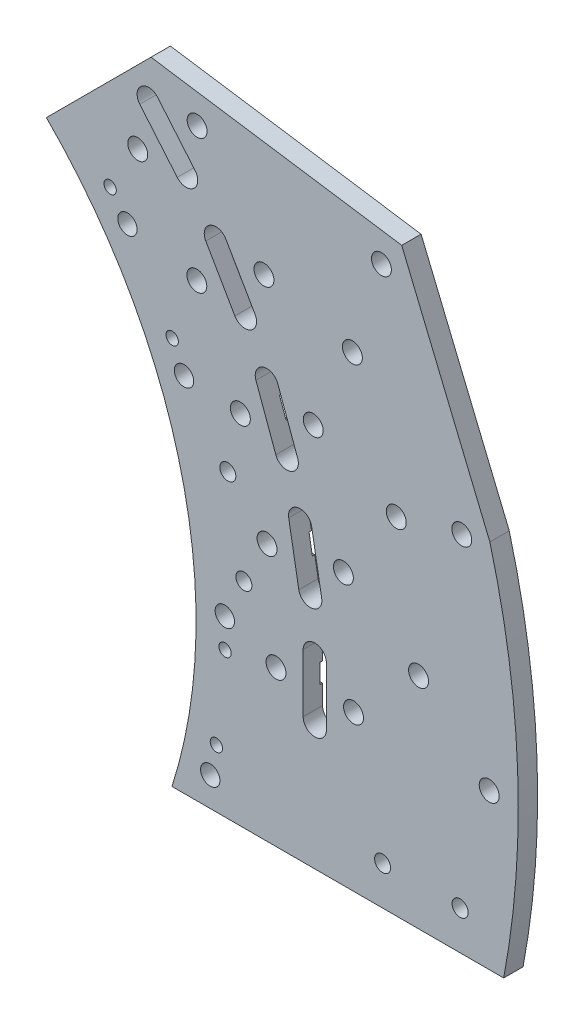
from build123d import *

# Parameters (mm, degrees)
SKETCH1_R           = 3.175
SKETCH1_R_2         = 3.2639
SKETCH1_R_3         = 2.6289
SKETCH1_R_4         = 2.0193
BOSS_EXTRUDE1_DEPTH = 6.35
SKETCH2_R           = 3.175
CUT_EXTRUDE1_DEPTH  = 0.79375


with BuildPart() as part:
    # Sketch1 → Boss-Extrude1 (new body)
    with BuildSketch(Plane.XY):
        with BuildLine():
            Line((159.591131024, -50.8), (268.282803213, -50.8))
            ThreePointArc((268.282803213, -50.8), (272.859757692, 10.190933821), (263.746046868, 70.670540265))
            Line((263.746046868, 70.670540265), (234.864133392, 140.397647486))
            Line((234.864133392, 140.397647486), (234.123018172, 140.508771477))
            Line((234.123018172, 140.508771477), (152.715190262, 152.715190262))
            Line((152.715190262, 152.715190262), (118.427127597, 118.427127597))
            ThreePointArc((118.427127597, 118.427127597), (154.732498954, 64.092299607), (167.48125, 0))
            ThreePointArc((167.48125, 0), (165.496965553, -25.70454229), (159.591131024, -50.8))
        make_face()
        with Locations((176.898422575, 6.177429038)):
            Circle(SKETCH1_R, mode=Mode.SUBTRACT)
        with Locations((144.995031539, 101.526614087)):
            Circle(SKETCH1_R, mode=Mode.SUBTRACT)
        with Locations((163.532451502, 67.7373593)):
            Circle(SKETCH1_R, mode=Mode.SUBTRACT)
        with Locations((172.12665951, -41.275)):
            Circle(SKETCH1_R, mode=Mode.SUBTRACT)
        with Locations((193.675, 0)):
            Circle(SKETCH1_R_2, mode=Mode.SUBTRACT)
        with Locations((219.075, 0)):
            Circle(SKETCH1_R_2, mode=Mode.SUBTRACT)
        with Locations((215.746758491, 38.041974522)):
            Circle(SKETCH1_R_2, mode=Mode.SUBTRACT)
        with Locations((190.732641565, 33.63131081)):
            Circle(SKETCH1_R_2, mode=Mode.SUBTRACT)
        with Locations((205.863160899, 74.928062899)):
            Circle(SKETCH1_R_2, mode=Mode.SUBTRACT)
        with Locations((181.994968331, 66.240751259)):
            Circle(SKETCH1_R_2, mode=Mode.SUBTRACT)
        with Locations((189.724515334, 109.5375)):
            Circle(SKETCH1_R_2, mode=Mode.SUBTRACT)
        with Locations((167.727470078, 96.8375)):
            Circle(SKETCH1_R_2, mode=Mode.SUBTRACT)
        with Locations((167.821186376, 140.818695592)):
            Circle(SKETCH1_R_2, mode=Mode.SUBTRACT)
        with Locations((148.363657521, 124.491890306)):
            Circle(SKETCH1_R_2, mode=Mode.SUBTRACT)
        with Locations((263.525, 0)):
            Circle(SKETCH1_R_2, mode=Mode.SUBTRACT)
        with Locations((254.545603373, 68.205288861)):
            Circle(SKETCH1_R_2, mode=Mode.SUBTRACT)
        with Locations((228.219344532, 131.7625)):
            Circle(SKETCH1_R_2, mode=Mode.SUBTRACT)
        with Locations((177.875240911, 47.661527156)):
            Circle(SKETCH1_R_3, mode=Mode.SUBTRACT)
        with Locations((183.141207032, 19.248916511)):
            Circle(SKETCH1_R_3, mode=Mode.SUBTRACT)
        with Locations((139.323763183, 109.179217581)):
            Circle(SKETCH1_R_4, mode=Mode.SUBTRACT)
        with Locations((159.651941396, 76.436052669)):
            Circle(SKETCH1_R_4, mode=Mode.SUBTRACT)
        with Locations((176.974598028, -3.347266353)):
            Circle(SKETCH1_R_4, mode=Mode.SUBTRACT)
        with Locations((174.135237045, -31.751090662)):
            Circle(SKETCH1_R_4, mode=Mode.SUBTRACT)
        with Locations((240.38178065, 21.030680725)):
            Circle(SKETCH1_R_2, mode=Mode.SUBTRACT)
        with Locations((233.077901884, 62.453035583)):
            Circle(SKETCH1_R_2, mode=Mode.SUBTRACT)
        with Locations((218.692069012, 101.977786558)):
            Circle(SKETCH1_R_2, mode=Mode.SUBTRACT)
        with Locations((228.6, -38.1)):
            Circle(SKETCH1_R_3, mode=Mode.SUBTRACT)
        with Locations((254, -38.1)):
            Circle(SKETCH1_R_3, mode=Mode.SUBTRACT)
        with BuildLine():
            Line((202.565, 0), (202.565, 9.525))
            ThreePointArc((202.565, 9.525), (206.375, 13.335), (210.185, 9.525))
            Line((210.185, 9.525), (210.185, 0))
            Line((210.185, 0), (210.185, -9.525))
            ThreePointArc((210.185, -9.525), (206.375, -13.335), (202.565, -9.525))
            Line((202.565, -9.525), (202.565, 0))
        make_face(mode=Mode.SUBTRACT)
        with BuildLine():
            Line((199.487582489, 35.175043109), (201.141581381, 25.794749262))
            ThreePointArc((201.141581381, 25.794749262), (205.555298477, 22.70423128), (208.645816459, 27.117948375))
            Line((208.645816459, 27.117948375), (206.991817567, 36.498242223))
            Line((206.991817567, 36.498242223), (205.337818675, 45.87853607))
            ThreePointArc((205.337818675, 45.87853607), (200.924101579, 48.969054052), (197.833583597, 44.555336957))
            Line((197.833583597, 44.555336957), (199.487582489, 35.175043109))
        make_face(mode=Mode.SUBTRACT)
        with BuildLine():
            Line((190.348835729, 69.281310333), (193.606577595, 60.33073812))
            ThreePointArc((193.606577595, 60.33073812), (198.489903226, 58.053605981), (200.767035365, 62.936931612))
            Line((200.767035365, 62.936931612), (197.5092935, 71.887503825))
            Line((197.5092935, 71.887503825), (194.251551635, 80.838076038))
            ThreePointArc((194.251551635, 80.838076038), (189.368226003, 83.115208177), (187.091093864, 78.231882546))
            Line((187.091093864, 78.231882546), (190.348835729, 69.281310333))
        make_face(mode=Mode.SUBTRACT)
        with BuildLine():
            Line((175.426435918, 101.2825), (180.188935918, 93.033608029))
            ThreePointArc((180.188935918, 93.033608029), (185.393492706, 91.639051241), (186.788049494, 96.843608029))
            Line((186.788049494, 96.843608029), (182.025549494, 105.0925))
            Line((182.025549494, 105.0925), (177.263049494, 113.341391971))
            ThreePointArc((177.263049494, 113.341391971), (172.058492706, 114.735948759), (170.663935918, 109.531391971))
            Line((170.663935918, 109.531391971), (175.426435918, 101.2825))
        make_face(mode=Mode.SUBTRACT)
        with BuildLine():
            Line((155.17379262, 130.206272156), (161.296344603, 122.909698835))
            ThreePointArc((161.296344603, 122.909698835), (166.663994724, 122.4400903), (167.133603259, 127.807740421))
            Line((167.133603259, 127.807740421), (161.011051277, 135.104313742))
            Line((161.011051277, 135.104313742), (154.888499295, 142.400887063))
            ThreePointArc((154.888499295, 142.400887063), (149.520849174, 142.870495598), (149.051240638, 137.502845477))
            Line((149.051240638, 137.502845477), (155.17379262, 130.206272156))
        make_face(mode=Mode.SUBTRACT)
    extrude(amount=BOSS_EXTRUDE1_DEPTH)

    # Sketch2 → Cut-Extrude1 (cut)
    with BuildSketch(Plane.XY):
        with Locations((202.565, 0)):
            Circle(SKETCH2_R)
        with Locations((210.185, 0)):
            Circle(SKETCH2_R)
        with Locations((199.487582489, 35.175043109)):
            Circle(SKETCH2_R)
        with Locations((206.991817567, 36.498242223)):
            Circle(SKETCH2_R)
        with Locations((190.348835729, 69.281310333)):
            Circle(SKETCH2_R)
        with Locations((197.5092935, 71.887503825)):
            Circle(SKETCH2_R)
        with Locations((175.426435918, 101.2825)):
            Circle(SKETCH2_R)
        with Locations((182.025549494, 105.0925)):
            Circle(SKETCH2_R)
        with Locations((155.17379262, 130.206272156)):
            Circle(SKETCH2_R)
        with Locations((161.011051277, 135.104313742)):
            Circle(SKETCH2_R)
    extrude(amount=CUT_EXTRUDE1_DEPTH, mode=Mode.SUBTRACT)


solid = part.part
